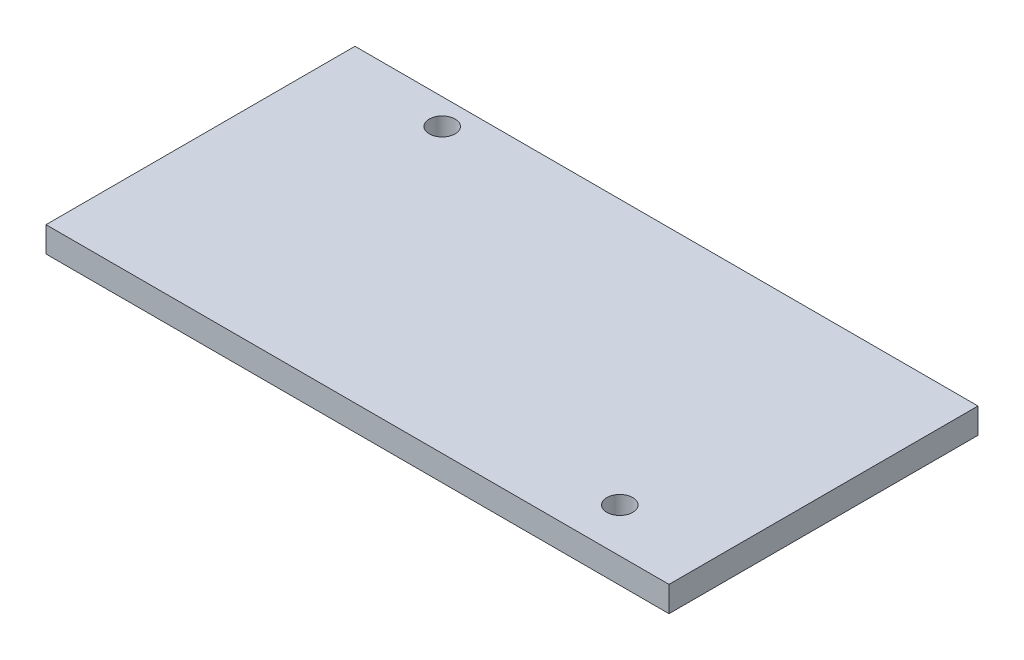
from build123d import *

# Parameters (mm, degrees)
SKETCH1_W           = 49
SKETCH1_H           = 24.3
BOSS_EXTRUDE1_DEPTH = 2
SKETCH2_R           = 1.015
CUT_EXTRUDE1_DEPTH  = 3


with BuildPart() as part:
    # Sketch1 → Boss-Extrude1 (new body)
    with BuildSketch(Plane(origin=(0, 0, 0), x_dir=(1, 0, 0), z_dir=(0, 1, 0))):
        with Locations((24.5, -12.15)):
            Rectangle(SKETCH1_W, SKETCH1_H)
    extrude(amount=BOSS_EXTRUDE1_DEPTH)

    # Sketch2 → Cut-Extrude1 (cut, through all)
    with BuildSketch(Plane(origin=(0, 2, 0), x_dir=(1, 0, 0), z_dir=(0, 1, 0))):
        with Locations((8.89, -2.032)):
            Circle(SKETCH2_R)
        with Locations((41.656, -20.828)):
            Circle(SKETCH2_R)
    extrude(amount=-CUT_EXTRUDE1_DEPTH, mode=Mode.SUBTRACT)


solid = part.part
